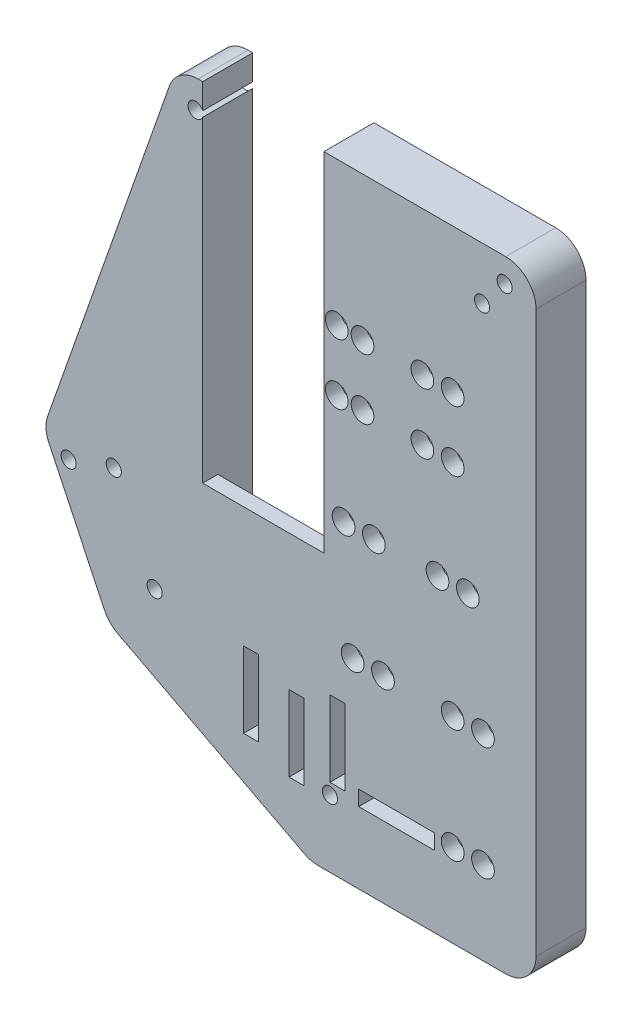
from build123d import *

# Parameters (mm, degrees)
BOSS_EXTRUDE1_DEPTH     = 2.54
SKETCH4_R               = 1.905
SKETCH4_W               = 20.32
SKETCH4_H               = 50.8
CUT_EXTRUDE2_DEPTH      = 25.4
SKETCH5_W               = 20.32
SKETCH5_H               = 7.493
CUT_EXTRUDE3_DEPTH      = 5.08
SKETCH8_W               = 12.7
SKETCH8_H               = 2.54
SKETCH8_W_2             = 2.54
SKETCH8_H_2             = 12.7
CUT_EXTRUDE5_DEPTH      = 5.08
BOSS_EXTRUDE2_DEPTH     = 5.842
SKETCH10_R              = 1.27
CUT_EXTRUDE6_DEPTH      = 1
CUT_EXTRUDE6_DEPTH_BACK = 9.382
SKETCH6_R               = 1.27
CUT_EXTRUDE7_DEPTH      = 1
CUT_EXTRUDE7_DEPTH_BACK = 9.382


with BuildPart() as part:
    # Sketch1 → Boss-Extrude1 (new body)
    with BuildSketch(Plane.XY):
        with BuildLine():
            Line((-3.314058103, 6.35), (48.26, 6.35))
            ThreePointArc((48.26, 6.35), (51.852102448, 4.862102448), (53.34, 1.27))
            Line((53.34, 1.27), (53.34, -92.71))
            ThreePointArc((53.34, -92.71), (51.852102448, -96.302102448), (48.26, -97.79))
            Line((48.26, -97.79), (16.846989059, -97.79))
            ThreePointArc((16.846989059, -97.79), (15.638688158, -97.644208035), (14.499741809, -97.215200367))
            Line((14.499741809, -97.215200367), (-16.7505185, -80.933552139))
            ThreePointArc((-16.7505185, -80.933552139), (-18.059258376, -79.955412607), (-18.989802686, -78.61241436))
            Line((-18.989802686, -78.61241436), (-28.309569459, -59.040904135))
            ThreePointArc((-28.309569459, -59.040904135), (-28.795802898, -57.127870198), (-28.51617555, -55.173917704))
            Line((-28.51617555, -55.173917704), (-8.107195629, 2.952923842))
            ThreePointArc((-8.107195629, 2.952923842), (-6.251501454, 5.414614163), (-3.314058103, 6.35))
        make_face()
    extrude(amount=BOSS_EXTRUDE1_DEPTH)

    # Sketch4 → Cut-Extrude2 (cut)
    with BuildSketch(Plane(origin=(0, 0, 0), x_dir=(-1, 0, 0), z_dir=(0, 0, -1))):
        with Locations((-39.37, -17.78)):
            Circle(SKETCH4_R)
        with Locations((-34.29, -17.78)):
            Circle(SKETCH4_R)
        with Locations((-39.37, -27.94)):
            Circle(SKETCH4_R)
        with Locations((-34.29, -27.94)):
            Circle(SKETCH4_R)
        with Locations((-41.91, -45.72)):
            Circle(SKETCH4_R)
        with Locations((-36.83, -45.72)):
            Circle(SKETCH4_R)
        with Locations((-44.45, -64.77)):
            Circle(SKETCH4_R)
        with Locations((-39.37, -64.77)):
            Circle(SKETCH4_R)
        with Locations((-44.45, -83.82)):
            Circle(SKETCH4_R)
        with Locations((-39.37, -83.82)):
            Circle(SKETCH4_R)
        with Locations((-24.257, -17.78)):
            Circle(SKETCH4_R)
        with Locations((-19.939, -17.78)):
            Circle(SKETCH4_R)
        with Locations((-24.257, -27.94)):
            Circle(SKETCH4_R)
        with Locations((-19.939, -27.94)):
            Circle(SKETCH4_R)
        with Locations((-26.162, -45.72)):
            Circle(SKETCH4_R)
        with Locations((-21.082, -45.72)):
            Circle(SKETCH4_R)
        with Locations((-27.686, -64.77)):
            Circle(SKETCH4_R)
        with Locations((-22.606, -64.77)):
            Circle(SKETCH4_R)
        with Locations((-7.62, -26.543)):
            Rectangle(SKETCH4_W, SKETCH4_H)
    extrude(amount=-CUT_EXTRUDE2_DEPTH, mode=Mode.SUBTRACT)

    # Sketch5 → Cut-Extrude3 (cut)
    with BuildSketch(Plane.XY.offset(2.54)):
        with Locations((7.62, 2.6035)):
            Rectangle(SKETCH5_W, SKETCH5_H)
    extrude(amount=-CUT_EXTRUDE3_DEPTH, mode=Mode.SUBTRACT)

    # Sketch8 → Cut-Extrude5 (cut)
    with BuildSketch(Plane.XY.offset(2.54)):
        with Locations((29.972, -84.5566)):
            Rectangle(SKETCH8_W, SKETCH8_H)
        with Locations((20.066, -78.359)):
            Rectangle(SKETCH8_W_2, SKETCH8_H_2)
        with Locations((13.208, -81.026)):
            Rectangle(SKETCH8_W_2, SKETCH8_H_2)
        with Locations((5.588, -78.486)):
            Rectangle(SKETCH8_W_2, SKETCH8_H_2)
    extrude(amount=-CUT_EXTRUDE5_DEPTH, mode=Mode.SUBTRACT)

    # Sketch9 → Boss-Extrude2 (add)
    with BuildSketch(Plane(origin=(0, 0, 0), x_dir=(-1, 0, 0), z_dir=(0, 0, -1))):
        with BuildLine():
            Line((-48.26, -97.79), (-48.26, 1.27))
            Line((-48.26, 1.27), (-17.78, 1.27))
            Line((-17.78, 1.27), (-17.78, 6.35))
            Line((-17.78, 6.35), (-48.26, 6.35))
            ThreePointArc((-48.26, 6.35), (-51.852102448, 4.862102448), (-53.34, 1.27))
            Line((-53.34, 1.27), (-53.34, -92.71))
            ThreePointArc((-53.34, -92.71), (-51.852102448, -96.302102448), (-48.26, -97.79))
        make_face()
        with BuildLine():
            Line((2.54, 0.820424909), (2.54, -82.609215784))
            Line((2.54, -82.609215784), (-16.846989059, -92.71))
            Line((-16.846989059, -92.71), (-16.846989059, -97.79))
            ThreePointArc((-16.846989059, -97.79), (-15.638688158, -97.644208035), (-14.499741809, -97.215200367))
            Line((-14.499741809, -97.215200367), (16.7505185, -80.933552139))
            ThreePointArc((16.7505185, -80.933552139), (18.059258376, -79.955412607), (18.989802686, -78.61241436))
            Line((18.989802686, -78.61241436), (28.309569459, -59.040904135))
            ThreePointArc((28.309569459, -59.040904135), (28.795802898, -57.127870198), (28.51617555, -55.173917704))
            Line((28.51617555, -55.173917704), (8.107195629, 2.952923842))
            ThreePointArc((8.107195629, 2.952923842), (6.251501454, 5.414614163), (3.314058103, 6.35))
            Line((3.314058103, 6.35), (2.54, 6.35))
            Line((2.54, 6.35), (2.54, 0.820424909))
        make_face()
    extrude(amount=BOSS_EXTRUDE2_DEPTH)

    # Sketch10 → Cut-Extrude6 (cut, two sides)
    with BuildSketch(Plane.XY.offset(2.54)) as cut_extrude6_sk:
        with Locations((48.0822, 2.286)):
            Circle(SKETCH10_R)
        with Locations((-3.718687848, 1.651)):
            Circle(SKETCH10_R)
        with Locations((-25.012261453, -59.761967182)):
            Circle(SKETCH10_R)
    extrude(amount=CUT_EXTRUDE6_DEPTH, mode=Mode.SUBTRACT)
    extrude(cut_extrude6_sk.sketch, amount=-CUT_EXTRUDE6_DEPTH_BACK, mode=Mode.SUBTRACT)

    # Sketch6 → Cut-Extrude7 (cut, two sides)
    with BuildSketch(Plane.XY.offset(2.54)) as cut_extrude7_sk:
        with Locations((1.6002, -2.4384)):
            Circle(SKETCH6_R)
        with Locations((44.2976, -2.4384)):
            Circle(SKETCH6_R)
        with Locations((-17.4498, -57.15)):
            Circle(SKETCH6_R)
        with Locations((-10.5918, -71.3486)):
            Circle(SKETCH6_R)
        with Locations((18.796, -86.5378)):
            Circle(SKETCH6_R)
    extrude(amount=CUT_EXTRUDE7_DEPTH, mode=Mode.SUBTRACT)
    extrude(cut_extrude7_sk.sketch, amount=-CUT_EXTRUDE7_DEPTH_BACK, mode=Mode.SUBTRACT)


solid = part.part
